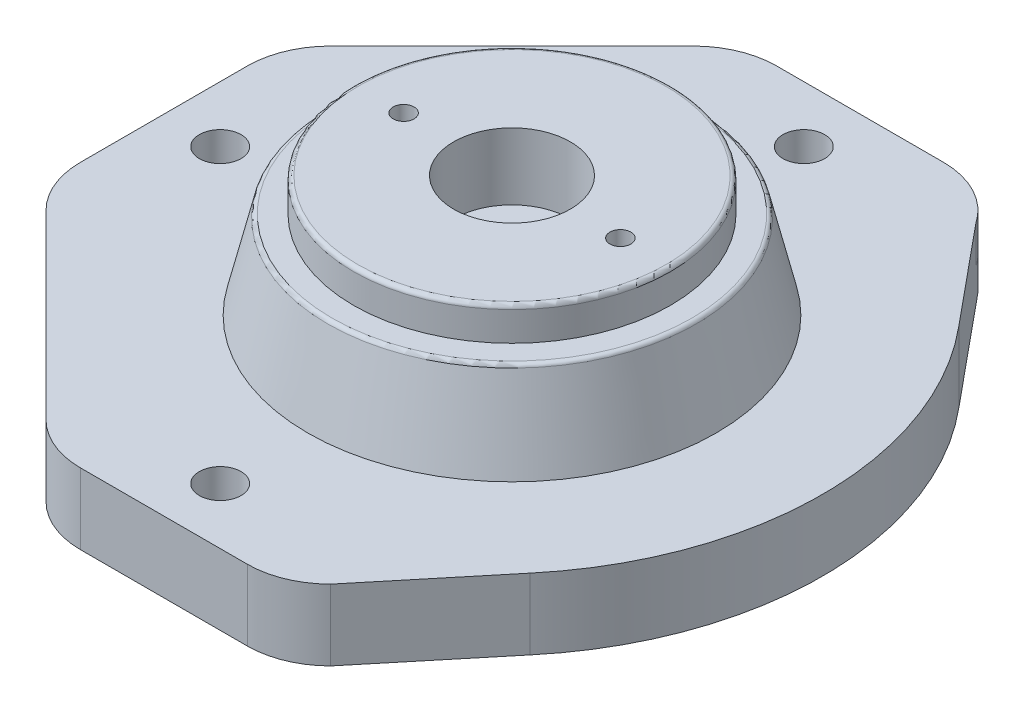
from build123d import *

# Parameters (mm, degrees)
SKETCH1_W           = 44
SKETCH1_H           = 14
SKETCH1_W_2         = 51
SKETCH1_H_2         = 2
SKETCH3_W           = 45
SKETCH3_H           = 2
SKETCH4_R           = 15
BOSS_EXTRUDE1_DEPTH = 6
SKETCH5_R           = 9.2
CUT_EXTRUDE3_DEPTH  = 7
SKETCH6_R           = 7
CUT_EXTRUDE4_DEPTH  = 27
FILLET1_R           = 2
SKETCH9_R           = 44
SKETCH9_R_2         = 38
CUT_EXTRUDE6_DEPTH  = 2
SKETCH13_R          = 38
SKETCH13_R_2        = 7
BOSS_EXTRUDE2_DEPTH = 6
FILLET5_R           = 1
SKETCH14_R          = 14
SKETCH14_R_2        = 7
CUT_EXTRUDE9_DEPTH  = 16
BOSS_EXTRUDE3_DEPTH = 9
SKETCH16_W          = 15
SKETCH16_H          = 10
SKETCH17_R          = 5
CUT_EXTRUDE11_DEPTH = 10
FILLET6_R           = 1
SKETCH26_W          = 3
SKETCH26_H          = 2
SKETCH29_R          = 48
SKETCH29_R_2        = 45
CUT_EXTRUDE12_DEPTH = 2
FILLET7_R           = 3
SKETCH34_R          = 5
SKETCH34_R_2        = 48
BOSS_EXTRUDE7_DEPTH = 8
CUT_EXTRUDE14_DEPTH = 8
CUT_EXTRUDE15_DEPTH = 18
SKETCH40_R          = 5
CUT_EXTRUDE16_DEPTH = 20
CUT_EXTRUDE17_DEPTH = 8


with BuildPart() as part:
    # Sketch1 → Revolve1 (revolve)
    with BuildSketch(Plane(origin=(0, 0, 0), x_dir=(0, 0, -1), z_dir=(1, 0, 0)), mode=Mode.PRIVATE) as revolve1_sk:
        with Locations((22, 25)):
            Rectangle(SKETCH1_W, SKETCH1_H)
        Polygon((44, 18), (0, 18), (0, 2), (51, 2), align=None)
        with Locations((25.5, 1)):
            Rectangle(SKETCH1_W_2, SKETCH1_H_2)
    revolve(revolve1_sk.sketch.rotate(Axis((0, 32.712152445, 0), (0, -1, 0)), 180), axis=Axis((0, 32.712152445, 0), (0, -1, 0)))

    # Sketch3 → Cut-Revolve1 (revolve, cut)
    with BuildSketch(Plane(origin=(0, 0, 0), x_dir=(0, 0, -1), z_dir=(1, 0, 0))):
        with Locations((22.5, 1)):
            Rectangle(SKETCH3_W, SKETCH3_H)
        Polygon((0, 18), (0, 2), (45, 2), (41, 18), align=None)
    revolve(axis=Axis((0, -18.749054984, 0), (0, 1, 0)), mode=Mode.SUBTRACT)

    # Sketch4 → Boss-Extrude1 (add)
    with BuildSketch(Plane(origin=(0, 18, 0), x_dir=(-1, 0, 0), z_dir=(0, -1, 0))):
        with Locations(Location((0, 0, 0), (0, 0, 90))):
            Circle(SKETCH4_R)
    extrude(amount=BOSS_EXTRUDE1_DEPTH)

    # Sketch5 → Cut-Extrude3 (cut)
    with BuildSketch(Plane.XZ.offset(-12)):
        with Locations(Location((0, 0, 0), (0, 0, 270))):
            Circle(SKETCH5_R)
    extrude(amount=-CUT_EXTRUDE3_DEPTH, mode=Mode.SUBTRACT)

    # Sketch6 → Cut-Extrude4 (cut)
    with BuildSketch(Plane.XZ.offset(-19)):
        with Locations(Location((0, 0, 0), (0, 0, 270))):
            Circle(SKETCH6_R)
    extrude(amount=-CUT_EXTRUDE4_DEPTH, mode=Mode.SUBTRACT)

    # Fillet1
    fillet1_edges = [part.edges().sort_by_distance(p)[0] for p in [
        (0, 19, 9.2),
    ]]
    fillet(fillet1_edges, radius=FILLET1_R)

    # Sketch9 → Cut-Extrude6 (cut)
    with BuildSketch(Plane(origin=(0, 32, 0), x_dir=(1, 0, 0), z_dir=(0, 1, 0))):
        with Locations(Location((0, 0, 0), (0, 0, 270))):
            Circle(SKETCH9_R)
        with Locations(Location((0, 0, 0), (0, 0, 270))):
            Circle(SKETCH9_R_2, mode=Mode.SUBTRACT)
    extrude(amount=-CUT_EXTRUDE6_DEPTH, mode=Mode.SUBTRACT)

    # Sketch13 → Boss-Extrude2 (add)
    with BuildSketch(Plane(origin=(0, 32, 0), x_dir=(1, 0, 0), z_dir=(0, 1, 0))):
        with Locations(Location((0, 0, 0), (0, 0, 270))):
            Circle(SKETCH13_R)
        with Locations(Location((0, 0, 0), (0, 0, 90))):
            Circle(SKETCH13_R_2, mode=Mode.SUBTRACT)
    extrude(amount=BOSS_EXTRUDE2_DEPTH)

    # Fillet5
    fillet5_edges = [part.edges().sort_by_distance(p)[0] for p in [
        (0, 38, -38),
    ]]
    fillet(fillet5_edges, radius=FILLET5_R)

    # Sketch14 → Cut-Extrude9 (cut)
    with BuildSketch(Plane(origin=(0, 38, 0), x_dir=(1, 0, 0), z_dir=(0, 1, 0))):
        with Locations(Location((0, 0, 0), (0, 0, 270))):
            Circle(SKETCH14_R)
        with Locations(Location((0, 0, 0), (0, 0, 90))):
            Circle(SKETCH14_R_2, mode=Mode.SUBTRACT)
    extrude(amount=-CUT_EXTRUDE9_DEPTH, mode=Mode.SUBTRACT)

    # Sketch15 → Boss-Extrude3 (add)
    with BuildSketch(Plane(origin=(0, 0, 0), x_dir=(1, 0, 0), z_dir=(0, 1, 0))):
        with BuildLine():
            Line((-77.642135624, -34.142135624), (-34.142135624, -77.642135624))
            ThreePointArc((-34.142135624, -77.642135624), (-27.653668647, -81.97759065), (-20, -83.5))
            Line((-20, -83.5), (20, -83.5))
            ThreePointArc((20, -83.5), (27.653668647, -81.97759065), (34.142135624, -77.642135624))
            Line((34.142135624, -77.642135624), (55.785028834, -51.421252812))
            ThreePointArc((55.785028834, -51.421252812), (74.5, 0), (55.785028834, 51.421252812))
            Line((55.785028834, 51.421252812), (36.56649078, 74.704971363))
            ThreePointArc((36.56649078, 74.704971363), (29.3781814, 81.164928917), (20, 83.5))
            Line((20, 83.5), (-20, 83.5))
            ThreePointArc((-20, 83.5), (-27.653668647, 81.97759065), (-34.142135624, 77.642135624))
            Line((-34.142135624, 77.642135624), (-77.642135624, 34.142135624))
            ThreePointArc((-77.642135624, 34.142135624), (-81.97759065, 27.653668647), (-83.5, 20))
            Line((-83.5, 20), (-83.5, -20))
            ThreePointArc((-83.5, -20), (-81.97759065, -27.653668647), (-77.642135624, -34.142135624))
        make_face()
    extrude(amount=BOSS_EXTRUDE3_DEPTH)

    # Sketch16 → Cut-Revolve3 (revolve, cut)
    with BuildSketch(Plane(origin=(0, 0, 0), x_dir=(0, 0, -1), z_dir=(1, 0, 0))):
        Polygon((15, 12), (15, 2), (48, 2), (41, 18), (15, 18), align=None)
        with Locations((7.5, 7)):
            Rectangle(SKETCH16_W, SKETCH16_H)
        Polygon((0, 2), (0, 0), (48, 0), (48, 2), (15, 2), align=None)
    revolve(axis=Axis((0, -11.590018377, 0), (0, 1, 0)), mode=Mode.SUBTRACT)

    # Sketch17 → Cut-Extrude11 (cut)
    with BuildSketch(Plane(origin=(0, 0, 0), x_dir=(-1, 0, 0), z_dir=(0, -1, 0))):
        with Locations(Location((0, 70, 0), (0, 0, 90))):
            Circle(SKETCH17_R)
        with Locations(Location((0, -70, 0), (0, 0, 90))):
            Circle(SKETCH17_R)
    extrude(amount=-CUT_EXTRUDE11_DEPTH, mode=Mode.SUBTRACT)

    # Sketch21 → Revolve3 (revolve)
    with BuildSketch(Plane(origin=(0, 0, 0), x_dir=(0, 0, -1), z_dir=(1, 0, 0)), mode=Mode.PRIVATE) as revolve3_sk:
        Polygon((40.904222375, 30), (45.904222375, 9), (49, 9), (44, 30), align=None)
    revolve(revolve3_sk.sketch.rotate(Axis((0, -11.272163733, 0), (0, 1, 0)), 180), axis=Axis((0, -11.272163733, 0), (0, 1, 0)))

    # Fillet6
    fillet6_edges = [part.edges().sort_by_distance(p)[0] for p in [
        (0, 30, -44),
    ]]
    fillet(fillet6_edges, radius=FILLET6_R)

    # Sketch26 → Revolve4 (revolve)
    with BuildSketch(Plane(origin=(0, 0, 0), x_dir=(0, 0, -1), z_dir=(1, 0, 0))):
        Polygon((48, 2), (45, 2), (41, 18), align=None)
        with Locations((46.5, 1)):
            Rectangle(SKETCH26_W, SKETCH26_H)
    revolve(axis=Axis((0, -14.846098764, 0), (0, 1, 0)))

    # Sketch29 → Cut-Extrude12 (cut)
    with BuildSketch(Plane(origin=(0, 0, 0), x_dir=(-1, 0, 0), z_dir=(0, -1, 0))):
        with Locations(Location((0, 0, 0), (0, 0, 90))):
            Circle(SKETCH29_R)
        Circle(SKETCH29_R_2, mode=Mode.SUBTRACT)
    extrude(amount=-CUT_EXTRUDE12_DEPTH, mode=Mode.SUBTRACT)

    # Fillet7
    fillet7_edges = [part.edges().sort_by_distance(p)[0] for p in [
        (0, 2, 45),
    ]]
    fillet(fillet7_edges, radius=FILLET7_R)

    # Sketch34 → Boss-Extrude7 (add)
    with BuildSketch(Plane.XZ):
        with BuildLine():
            Line((-77.642135624, -34.142135624), (-34.142135624, -77.642135624))
            ThreePointArc((-34.142135624, -77.642135624), (-27.653668647, -81.97759065), (-20, -83.5))
            Line((-20, -83.5), (20, -83.5))
            ThreePointArc((20, -83.5), (27.653668647, -81.97759065), (34.142135624, -77.642135624))
            Line((34.142135624, -77.642135624), (36.56649078, -74.704971363))
            Line((36.56649078, -74.704971363), (55.785028834, -51.421252812))
            ThreePointArc((55.785028834, -51.421252812), (74.5, 0), (55.785028834, 51.421252812))
            Line((55.785028834, 51.421252812), (36.56649078, 74.704971362))
            Line((36.56649078, 74.704971362), (34.142135624, 77.642135624))
            ThreePointArc((34.142135624, 77.642135624), (27.653668647, 81.97759065), (20, 83.5))
            Line((20, 83.5), (-20, 83.5))
            ThreePointArc((-20, 83.5), (-27.653668647, 81.97759065), (-34.142135624, 77.642135624))
            Line((-34.142135624, 77.642135624), (-77.642135624, 34.142135624))
            ThreePointArc((-77.642135624, 34.142135624), (-81.97759065, 27.653668647), (-83.5, 20))
            Line((-83.5, 20), (-83.5, -20))
            ThreePointArc((-83.5, -20), (-81.97759065, -27.653668647), (-77.642135624, -34.142135624))
        make_face()
        with Locations(Location((0, -70, 0), (0, 0, 270))):
            Circle(SKETCH34_R, mode=Mode.SUBTRACT)
        with Locations(Location((0, 0, 0), (0, 0, 270))):
            Circle(SKETCH34_R_2, mode=Mode.SUBTRACT)
        with Locations(Location((0, 70, 0), (0, 0, 270))):
            Circle(SKETCH34_R, mode=Mode.SUBTRACT)
    extrude(amount=BOSS_EXTRUDE7_DEPTH)

    # Sketch35 → Cut-Extrude14 (cut)
    with BuildSketch(Plane(origin=(0, -8, 0), x_dir=(-1, 0, 0), z_dir=(0, -1, 0))):
        Polygon((-9.814954576, 70), (-4.907477288, 61.5), (4.907477288, 61.5), (9.814954576, 70), (4.907477288, 78.5), (-4.907477288, 78.5), align=None)
        Polygon((-9.814954576, -70), (-4.907477288, -78.5), (4.907477288, -78.5), (9.814954576, -70), (4.907477288, -61.5), (-4.907477288, -61.5), align=None)
    extrude(amount=-CUT_EXTRUDE14_DEPTH, mode=Mode.SUBTRACT)

    # Sketch36 → Cut-Extrude15 (cut)
    with BuildSketch(Plane(origin=(0, 38, 0), x_dir=(1, 0, 0), z_dir=(0, 1, 0))):
        with BuildLine():
            ThreePointArc((28.5, 0), (26, 2.5), (23.5, 0))
            Line((23.5, 0), (28.5, 0))
        make_face()
        with BuildLine():
            Line((28.5, 0), (23.5, 0))
            ThreePointArc((23.5, 0), (26, -2.5), (28.5, 0))
        make_face()
        with BuildLine():
            ThreePointArc((-28.5, 0), (-26, -2.5), (-23.5, 0))
            Line((-23.5, 0), (-28.5, 0))
        make_face()
        with BuildLine():
            Line((-28.5, 0), (-23.5, 0))
            ThreePointArc((-23.5, 0), (-26, 2.5), (-28.5, 0))
        make_face()
    extrude(amount=-CUT_EXTRUDE15_DEPTH, mode=Mode.SUBTRACT)

    # Sketch40 → Cut-Extrude16 (cut)
    with BuildSketch(Plane.XZ.offset(8)):
        with Locations(Location((-70, 0, 0), (0, 0, 270))):
            Circle(SKETCH40_R)
    extrude(amount=-CUT_EXTRUDE16_DEPTH, mode=Mode.SUBTRACT)

    # Sketch41 → Cut-Extrude17 (cut)
    with BuildSketch(Plane(origin=(0, -8, 0), x_dir=(-1, 0, 0), z_dir=(0, -1, 0))):
        Polygon((70, 9.814954576), (61.5, 4.907477288), (61.5, -4.907477288), (70, -9.814954576), (78.5, -4.907477288), (78.5, 4.907477288), align=None)
    extrude(amount=-CUT_EXTRUDE17_DEPTH, mode=Mode.SUBTRACT)


solid = part.part
